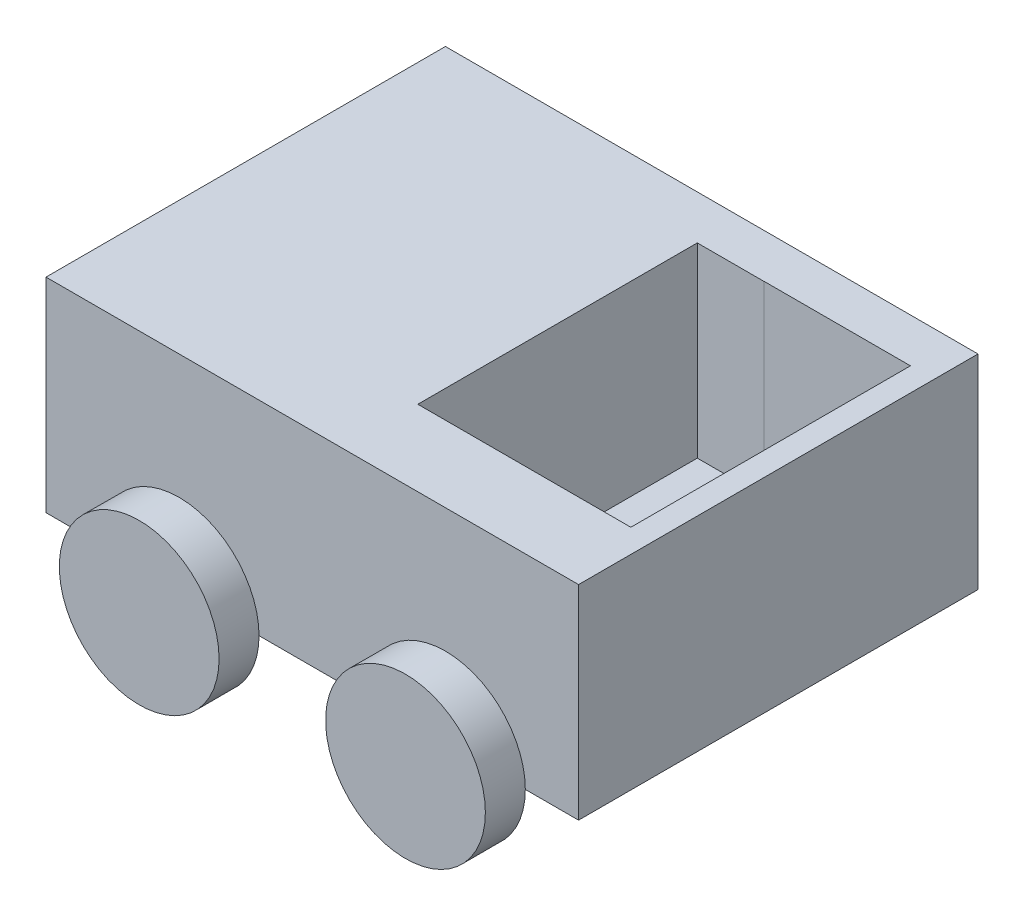
from build123d import *

# Parameters (mm, degrees)
SKETCH7_W           = 20
SKETCH7_H           = 7.663039205
BOSS_EXTRUDE2_DEPTH = 15
SKETCH8_W           = 5.5
SKETCH8_H           = 10.5
CUT_EXTRUDE3_DEPTH  = 7
SKETCH9_R           = 3
BOSS_EXTRUDE4_DEPTH = 1.5
SKETCH11_R          = 3
BOSS_EXTRUDE6_DEPTH = 1.5
SKETCH12_R          = 3
BOSS_EXTRUDE7_DEPTH = 1.5
SKETCH13_W          = 2.5
SKETCH13_H          = 10.495878043
CUT_EXTRUDE4_DEPTH  = 7


with BuildPart() as part:
    # Sketch7 → Boss-Extrude2 (new body)
    with BuildSketch(Plane.XY):
        with Locations((10, -3.831519603)):
            Rectangle(SKETCH7_W, SKETCH7_H)
    extrude(amount=BOSS_EXTRUDE2_DEPTH)

    # Sketch8 → Cut-Extrude3 (cut)
    with BuildSketch(Plane(origin=(0, 0, 0), x_dir=(1, 0, 0), z_dir=(0, 1, 0))):
        with Locations((16.367319257, -6.904304489)):
            Rectangle(SKETCH8_W, SKETCH8_H)
    extrude(amount=-CUT_EXTRUDE3_DEPTH, mode=Mode.SUBTRACT)

    # Sketch9 → Boss-Extrude4 (add)
    with BuildSketch(Plane.XY.offset(15)):
        with Locations((15, -7.663039205)):
            Circle(SKETCH9_R)
    extrude(amount=BOSS_EXTRUDE4_DEPTH)

    # Sketch11 → Boss-Extrude6 (add)
    with BuildSketch(Plane.XY.offset(15)):
        with Locations((5, -7.663039205)):
            Circle(SKETCH11_R)
    extrude(amount=BOSS_EXTRUDE6_DEPTH)

    # Sketch12 → Boss-Extrude7 (add)
    with BuildSketch(Plane(origin=(0, 0, 0), x_dir=(-1, 0, 0), z_dir=(0, 0, -1))):
        with Locations((-15, -7.663039205)):
            Circle(SKETCH12_R)
        with Locations((-5, -7.663039205)):
            Circle(SKETCH12_R)
    extrude(amount=BOSS_EXTRUDE7_DEPTH)

    # Sketch13 → Cut-Extrude4 (cut)
    with BuildSketch(Plane(origin=(0, 0, 0), x_dir=(1, 0, 0), z_dir=(0, 1, 0))):
        with Locations((12.367319257, -6.906365468)):
            Rectangle(SKETCH13_W, SKETCH13_H)
    extrude(amount=-CUT_EXTRUDE4_DEPTH, mode=Mode.SUBTRACT)


solid = part.part
